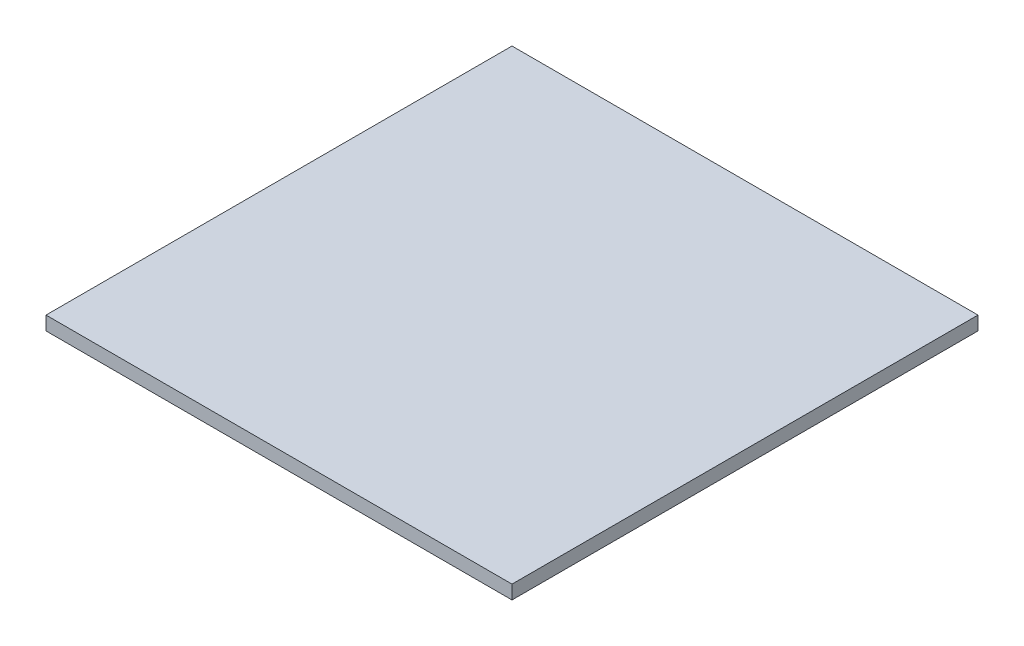
from build123d import *

# Parameters (mm, degrees)
SKETCH_1_W      = 50.8
SKETCH_1_H      = 50.8
EXTRUDE_1_DEPTH = 1.5


with BuildPart() as part:
    # 草图1 → 凸台-拉伸1 (new body)
    with BuildSketch(Plane(origin=(0, 0, 0), x_dir=(1, 0, 0), z_dir=(0, 1, 0))):
        Rectangle(SKETCH_1_W, SKETCH_1_H)
    extrude(amount=EXTRUDE_1_DEPTH)


solid = part.part
